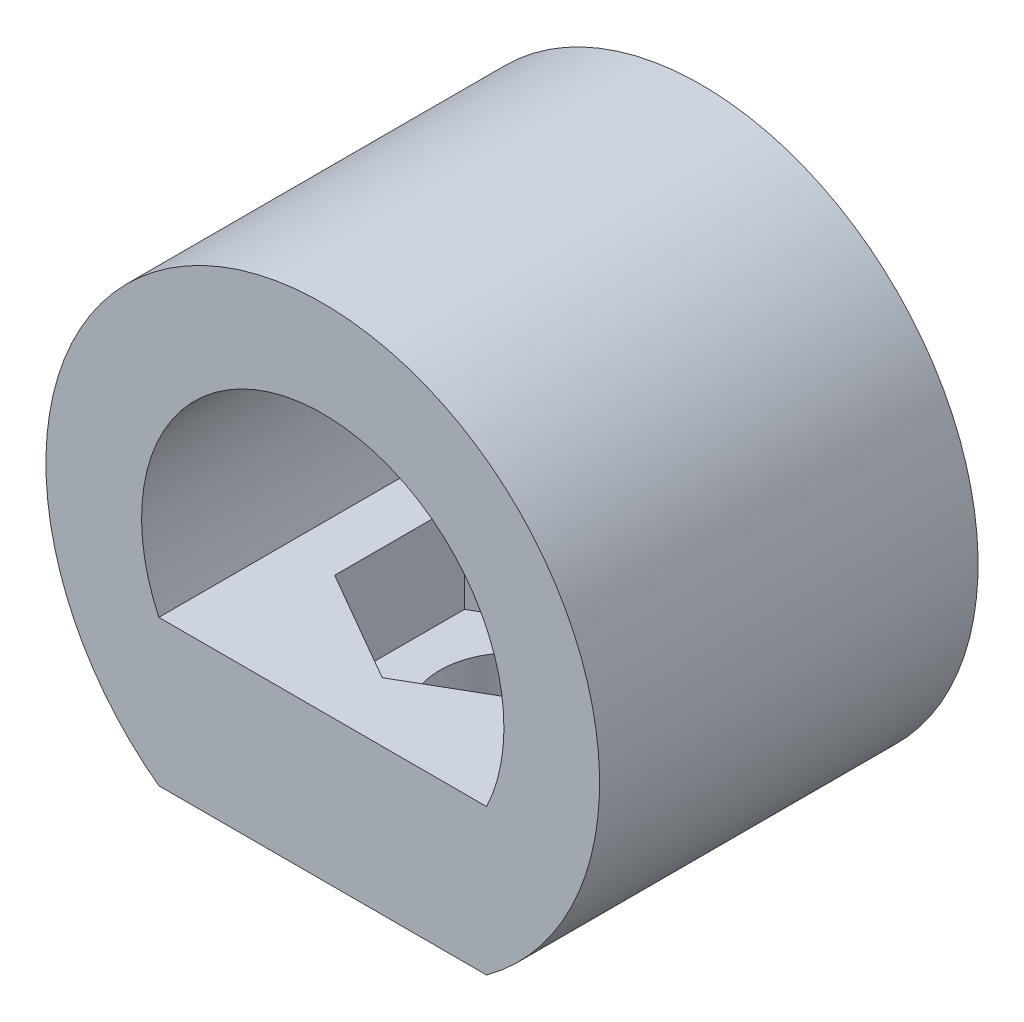
from build123d import *

# Parameters (mm, degrees)
BOSS_EXTRU_1_DEPTH = 5.5
ESQUISSE5_W        = 19.1
ESQUISSE5_H        = 22.054780284
ESQUISSE5_R        = 4.2
BOSS_EXTRU_7_DEPTH = 3
BOSS_EXTRU_8_START = -11.02739
BOSS_EXTRU_8_DEPTH = 22.05478


with BuildPart() as part:
    # Esquisse1 → Boss.-Extru.1 (new body)
    with BuildSketch(Plane(origin=(0, 0, 0), x_dir=(1, 0, 0), z_dir=(0, 1, 0))):
        Polygon((-9.55, -5.513695071), (0, -11.027390142), (9.55, -5.513695071), (9.55, 5.513695071), (0, 11.027390142), (-9.55, 5.513695071), align=None)
        Polygon((0, -7.563288526), (6.55, -3.781644263), (6.55, 3.781644263), (0, 7.563288526), (-6.55, 3.781644263), (-6.55, -3.781644263), align=None, mode=Mode.SUBTRACT)
        Polygon((-9.55, -11.027390142), (0, -11.027390142), (-9.55, -5.513695071), align=None)
        Polygon((-9.55, 5.513695071), (0, 11.027390142), (-9.55, 11.027390142), align=None)
        Polygon((0, 11.027390142), (9.55, 5.513695071), (9.55, 11.027390142), align=None)
        Polygon((9.55, -11.027390142), (9.55, -5.513695071), (0, -11.027390142), align=None)
    extrude(amount=BOSS_EXTRU_1_DEPTH)

    # Esquisse5 → Boss.-Extru.7 (add)
    with BuildSketch(Plane(origin=(0, 0, 0), x_dir=(-1, 0, 0), z_dir=(0, -1, 0))):
        Rectangle(ESQUISSE5_W, ESQUISSE5_H)
        Circle(ESQUISSE5_R, mode=Mode.SUBTRACT)
    extrude(amount=BOSS_EXTRU_7_DEPTH)

    # Esquisse6 → Boss.-Extru.8 (add)
    with BuildSketch(Plane.XY.offset(BOSS_EXTRU_8_START)):
        with BuildLine():
            ThreePointArc((16.130793533, 10), (-7.285376509, 24.39186538), (-9.55, -3))
            Line((-9.55, -3), (-9.55, 5.5))
            ThreePointArc((-9.55, 5.5), (-2.305659544, 20.302253834), (10.557106611, 10))
            ThreePointArc((10.557106611, 10), (10.302253834, 7.694340456), (9.55, 5.5))
            Line((9.55, 5.5), (9.55, -3))
            ThreePointArc((9.55, -3), (14.39186538, 2.714623491), (16.130793533, 10))
        make_face()
    extrude(amount=BOSS_EXTRU_8_DEPTH)


solid = part.part
